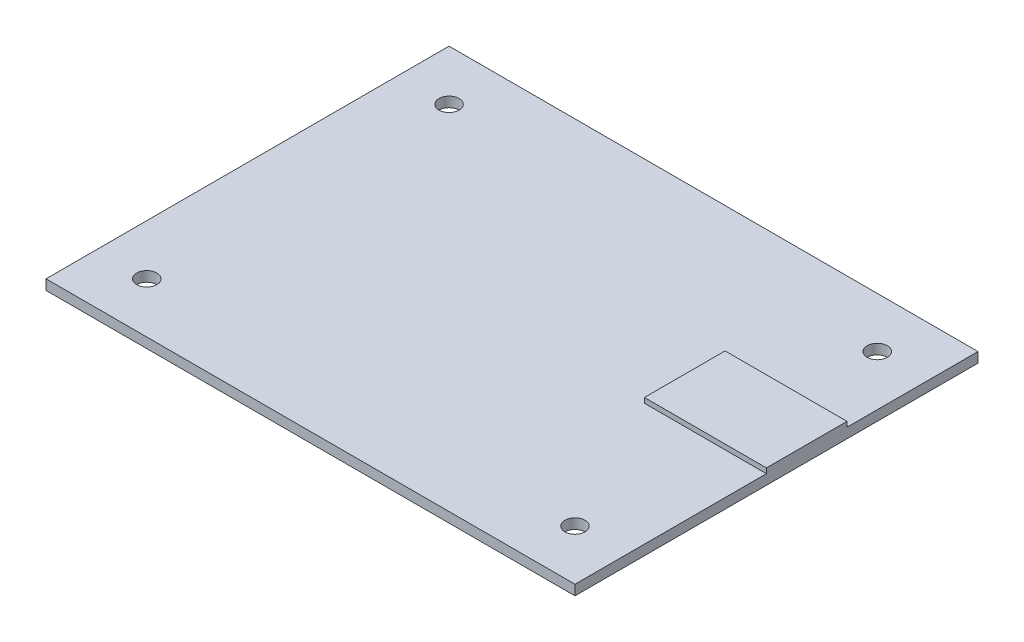
from build123d import *

# Parameters (mm, degrees)
CROQUIS1_W              = 105
CROQUIS1_H              = 80
CROQUIS1_R              = 2
SALIENTE_EXTRUIR1_DEPTH = 2
CROQUIS2_W              = 24.213032347
CROQUIS2_H              = 16
SALIENTE_EXTRUIR2_DEPTH = 3


with BuildPart() as part:
    # Croquis1 → Saliente-Extruir1 (new body)
    with BuildSketch(Plane(origin=(0, 0, 0), x_dir=(1, 0, 0), z_dir=(0, 1, 0))):
        Rectangle(CROQUIS1_W, CROQUIS1_H)
        with Locations((-42.5, 30)):
            Circle(CROQUIS1_R, mode=Mode.SUBTRACT)
        with Locations((-42.5, -30)):
            Circle(CROQUIS1_R, mode=Mode.SUBTRACT)
        with Locations((42.5, -30)):
            Circle(CROQUIS1_R, mode=Mode.SUBTRACT)
        with Locations((42.5, 30)):
            Circle(CROQUIS1_R, mode=Mode.SUBTRACT)
    extrude(amount=SALIENTE_EXTRUIR1_DEPTH)

    # Croquis2 → Saliente-Extruir2 (add)
    with BuildSketch(Plane(origin=(0, 0, 0), x_dir=(1, 0, 0), z_dir=(0, 1, 0))):
        with Locations((40.393483827, 6)):
            Rectangle(CROQUIS2_W, CROQUIS2_H)
    extrude(amount=SALIENTE_EXTRUIR2_DEPTH)


solid = part.part
